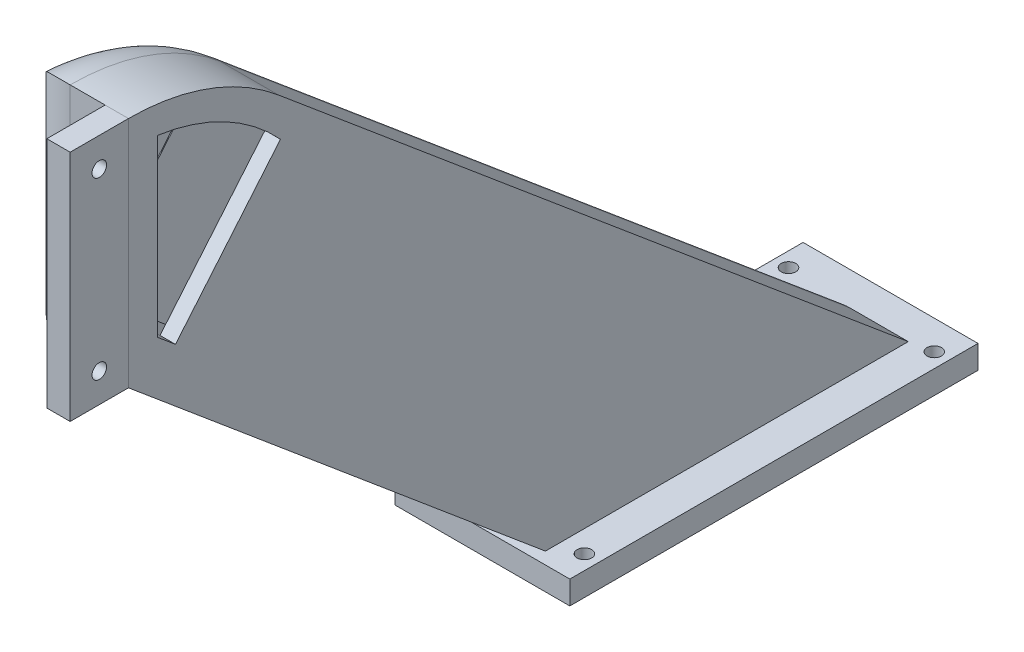
from build123d import *

# Parameters (mm, degrees)
SKETCH1_W           = 10
SKETCH1_H           = 20
SKETCH1_R           = 1.25
BOSS_EXTRUDE1_DEPTH = 4
BOSS_EXTRUDE2_DEPTH = 20
FILLET2_R           = 10
SKETCH3_R           = 1.25
CUT_EXTRUDE1_DEPTH  = 15
SKETCH4_W           = 12.205542936
SKETCH4_H           = 28.274710975
CUT_EXTRUDE2_DEPTH  = 137.397289148
SKETCH5_W           = 30
SKETCH5_H           = 70
SKETCH5_R           = 1.25
SKETCH5_W_2         = 12.205542936
SKETCH5_H_2         = 43.987641562
BOSS_EXTRUDE3_DEPTH = 4


with BuildPart() as part:
    # Sketch1 → Boss-Extrude1 (new body)
    with BuildSketch(Plane(origin=(0, 0, 0), x_dir=(0, 0, -1), z_dir=(1, 0, 0))):
        with Locations((5, -10)):
            Rectangle(SKETCH1_W, SKETCH1_H)
        with Locations((5, -15)):
            Circle(SKETCH1_R, mode=Mode.SUBTRACT)
        with Locations((5, 10)):
            Rectangle(SKETCH1_W, SKETCH1_H)
        with Locations((5, 15)):
            Circle(SKETCH1_R, mode=Mode.SUBTRACT)
    extrude(amount=BOSS_EXTRUDE1_DEPTH)


with BuildPart() as body_2:
    # Sketch2 → Boss-Extrude2 (new body)
    with BuildSketch(Plane(origin=(4, 0, 0), x_dir=(0, 0, -1), z_dir=(1, 0, 0))):
        with BuildLine():
            ThreePointArc((10, 20), (23.680805733, 17.587704831), (35.711504387, 10.641777725))
            Line((35.711504387, 10.641777725), (143.73416863, -80))
            Line((143.73416863, -80), (81.505215556, -80))
            Line((81.505215556, -80), (10, -20))
            Line((10, -20), (10, 20))
        make_face()
    extrude(amount=-BOSS_EXTRUDE2_DEPTH)

    # Fillet2
    fillet2_edges = [body_2.edges().sort_by_distance(p)[0] for p in [
        (-16, 0, -10),
        (-16, -50, -45.752607778),
        (-16, -34.679111138, -89.722836509),
        (-16, 17.587704831, -23.680805733),
    ]]
    fillet(fillet2_edges, radius=FILLET2_R)

    # Sketch3 → Cut-Extrude1 (cut)
    with BuildSketch(Plane(origin=(4, 0, 0), x_dir=(0, 0, -1), z_dir=(1, 0, 0))):
        with Locations((5, -15)):
            Circle(SKETCH3_R)
        with Locations((5, 15)):
            Circle(SKETCH3_R)
        with BuildLine():
            Line((15, 15), (15, -15))
            Line((15, -15), (18.064177772, -17.571150439))
            Line((18.064177772, -17.571150439), (36.067703055, 3.884615497))
            ThreePointArc((36.067703055, 3.884615497), (26.498135848, 11.269977831), (15, 15))
        make_face()
    extrude(amount=-CUT_EXTRUDE1_DEPTH, mode=Mode.SUBTRACT)

    # Sketch4 → Cut-Extrude2 (cut, through all)
    with BuildSketch(Plane(origin=(0, -16.154847254, -19.252597253), x_dir=(1, 0, 0), z_dir=(0, 0.64278761, 0.766044443))):
        with Locations((-4.757097635, 12.281851889)):
            Rectangle(SKETCH4_W, SKETCH4_H)
    extrude(amount=-CUT_EXTRUDE2_DEPTH, mode=Mode.SUBTRACT)

    # Sketch5 → Boss-Extrude3 (add)
    with BuildSketch(Plane.XZ.offset(80)):
        with Locations((-4.757097635, -114.447457028)):
            Rectangle(SKETCH5_W, SKETCH5_H)
        with Locations((-17.257097635, -84.447457028)):
            Circle(SKETCH5_R, mode=Mode.SUBTRACT)
        with Locations((7.742902365, -84.447457028)):
            Circle(SKETCH5_R, mode=Mode.SUBTRACT)
        with Locations((7.742902365, -144.447457028)):
            Circle(SKETCH5_R, mode=Mode.SUBTRACT)
        with Locations((-17.257097635, -144.447457028)):
            Circle(SKETCH5_R, mode=Mode.SUBTRACT)
        with Locations((-4.757097635, -114.447457028)):
            Rectangle(SKETCH5_W_2, SKETCH5_H_2, mode=Mode.SUBTRACT)
    extrude(amount=BOSS_EXTRUDE3_DEPTH)


solid = Compound([part.part, body_2.part])
